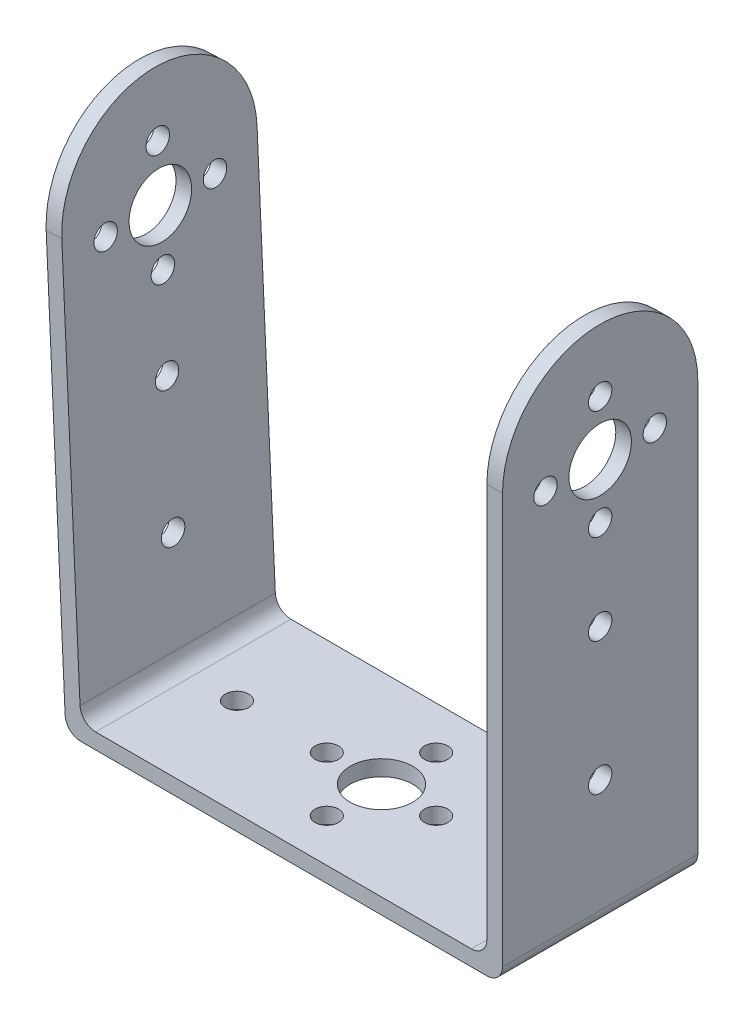
from build123d import *

# Parameters (mm, degrees)
BOSS_EXTRUDE1_DEPTH = 25
SKETCH4_R           = 4
SKETCH4_R_2         = 1.5
CUT_EXTRUDE3_DEPTH  = 2
SKETCH5_R           = 1.5
SKETCH5_R_2         = 4
CUT_EXTRUDE4_DEPTH  = 2
SKETCH6_R           = 4
SKETCH6_R_2         = 1.5
CUT_EXTRUDE5_DEPTH  = 2
FILLET2_R           = 2


with BuildPart() as part:
    # Sketch1 → Boss-Extrude1 (new body)
    with BuildSketch(Plane.XY):
        Polygon((27.999082786, 67), (25.999082786, 67), (25.999082786, 2), (-26.000917214, 2), (-29.000917214, 67), (-30.998790434, 66.907790467), (-27.910738566, 0), (-26.000917214, 0), (27.999082786, 0), align=None)
    extrude(amount=-BOSS_EXTRUDE1_DEPTH)

    # Sketch4 → Cut-Extrude3 (cut)
    with BuildSketch(Plane(origin=(-27.851410119, -1.285449698, 0), x_dir=(0, 0, 1), z_dir=(-0.99893661, -0.046104767, 0))):
        with BuildLine():
            Line((0, 68.265833379), (-12.5, 68.265833379))
            ThreePointArc((-12.5, 68.265833379), (-3.661165235, 64.604668144), (0, 55.765833379))
            Line((0, 55.765833379), (0, 68.265833379))
        make_face()
        with BuildLine():
            Line((-25, 68.265833379), (-25, 55.765833379))
            ThreePointArc((-25, 55.765833379), (-21.338834765, 64.604668144), (-12.5, 68.265833379))
            Line((-12.5, 68.265833379), (-25, 68.265833379))
        make_face()
        with Locations((-12.5, 53.286818087)):
            Circle(SKETCH4_R)
        with Locations((-12.5, 34.786818087)):
            Circle(SKETCH4_R_2)
        with Locations((-12.5, 17.786818087)):
            Circle(SKETCH4_R_2)
        with Locations((-12.5, 46.286818087)):
            Circle(SKETCH4_R_2)
        with Locations((-19.5, 53.286818087)):
            Circle(SKETCH4_R_2)
        with Locations((-12.5, 60.286818087)):
            Circle(SKETCH4_R_2)
        with Locations((-5.5, 53.286818087)):
            Circle(SKETCH4_R_2)
    extrude(amount=-CUT_EXTRUDE3_DEPTH, mode=Mode.SUBTRACT)

    # Sketch5 → Cut-Extrude4 (cut)
    with BuildSketch(Plane(origin=(27.999082786, 0, 0), x_dir=(0, 0, -1), z_dir=(1, 0, 0))):
        with BuildLine():
            Line((0, 67), (0, 54.5))
            ThreePointArc((0, 54.5), (3.661165235, 63.338834765), (12.5, 67))
            Line((12.5, 67), (0, 67))
        make_face()
        with BuildLine():
            Line((25, 67), (12.5, 67))
            ThreePointArc((12.5, 67), (21.338834765, 63.338834765), (25, 54.5))
            Line((25, 54.5), (25, 67))
        make_face()
        with Locations((12.5, 59)):
            Circle(SKETCH5_R)
        with Locations((19.5, 52)):
            Circle(SKETCH5_R)
        with Locations((12.5, 45)):
            Circle(SKETCH5_R)
        with Locations((5.5, 52)):
            Circle(SKETCH5_R)
        with Locations((12.5, 33.5)):
            Circle(SKETCH5_R)
        with Locations((12.5, 16.5)):
            Circle(SKETCH5_R)
        with Locations((12.5, 52)):
            Circle(SKETCH5_R_2)
    extrude(amount=-CUT_EXTRUDE4_DEPTH, mode=Mode.SUBTRACT)

    # Sketch6 → Cut-Extrude5 (cut)
    with BuildSketch(Plane(origin=(0, 2, 0), x_dir=(1, 0, 0), z_dir=(0, 1, 0))):
        with Locations((-0.000917214, 12.5)):
            Circle(SKETCH6_R)
        with Locations((-7.000917214, 12.5)):
            Circle(SKETCH6_R_2)
        with Locations((-0.000917214, 19.5)):
            Circle(SKETCH6_R_2)
        with Locations((6.999082786, 12.5)):
            Circle(SKETCH6_R_2)
        with Locations((-0.000917214, 5.5)):
            Circle(SKETCH6_R_2)
        with Locations((18.499082786, 12.5)):
            Circle(SKETCH6_R_2)
        with Locations((-18.500917214, 12.5)):
            Circle(SKETCH6_R_2)
    extrude(amount=-CUT_EXTRUDE5_DEPTH, mode=Mode.SUBTRACT)

    # Fillet2
    fillet2_edges = [part.edges().sort_by_distance(p)[0] for p in [
        (-27.910738566, 0, -12.5),
        (-26.000917214, 2, -12.5),
        (25.999082786, 2, -12.5),
        (27.999082786, 0, -12.5),
    ]]
    fillet(fillet2_edges, radius=FILLET2_R)


solid = part.part
